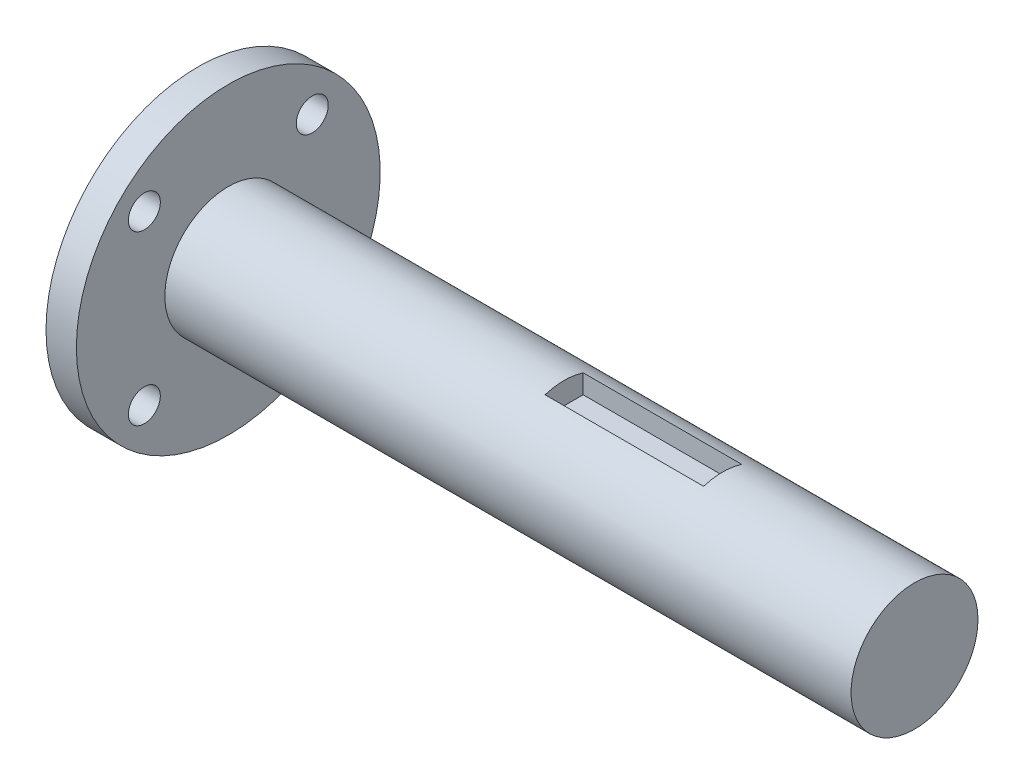
from build123d import *

# Parameters (mm, degrees)
SKETCH1_R           = 7.9375
BOSS_EXTRUDE1_DEPTH = 42
SKETCH4_R           = 19
SKETCH4_R_2         = 2
BOSS_EXTRUDE3_DEPTH = 3.8
BOSS_EXTRUDE5_DEPTH = 19.8272
SKETCH7_R           = 7.9375
BOSS_EXTRUDE6_DEPTH = 24


with BuildPart() as part:
    # Sketch1 → Boss-Extrude1 (new body)
    with BuildSketch(Plane(origin=(0, 0, 0), x_dir=(0, 0, -1), z_dir=(1, 0, 0))):
        Circle(SKETCH1_R)
    extrude(amount=BOSS_EXTRUDE1_DEPTH)

    # Sketch4 → Boss-Extrude3 (add)
    with BuildSketch(Plane.ZY):
        Circle(SKETCH4_R)
        with Locations((-10.5, 10.5)):
            Circle(SKETCH4_R_2, mode=Mode.SUBTRACT)
        with Locations((10.5, 10.5)):
            Circle(SKETCH4_R_2, mode=Mode.SUBTRACT)
        with Locations((10.5, -10.5)):
            Circle(SKETCH4_R_2, mode=Mode.SUBTRACT)
        with Locations((-10.5, -10.5)):
            Circle(SKETCH4_R_2, mode=Mode.SUBTRACT)
    extrude(amount=BOSS_EXTRUDE3_DEPTH)

    # Sketch6 → Boss-Extrude5 (add)
    with BuildSketch(Plane(origin=(42, 0, 0), x_dir=(0, 0, -1), z_dir=(1, 0, 0))):
        with BuildLine():
            Line((-2.3815, 5.188813785), (2.3815, 5.188813785))
            Line((2.3815, 5.188813785), (2.3815, 7.571813785))
            ThreePointArc((2.3815, 7.571813785), (0, -7.9375), (-2.3815, 7.571813785))
            Line((-2.3815, 7.571813785), (-2.3815, 5.188813785))
        make_face()
    extrude(amount=BOSS_EXTRUDE5_DEPTH)

    # Sketch7 → Boss-Extrude6 (add)
    with BuildSketch(Plane(origin=(61.8272, 0, 0), x_dir=(0, 0, -1), z_dir=(1, 0, 0))):
        Circle(SKETCH7_R)
    extrude(amount=BOSS_EXTRUDE6_DEPTH)


solid = part.part
